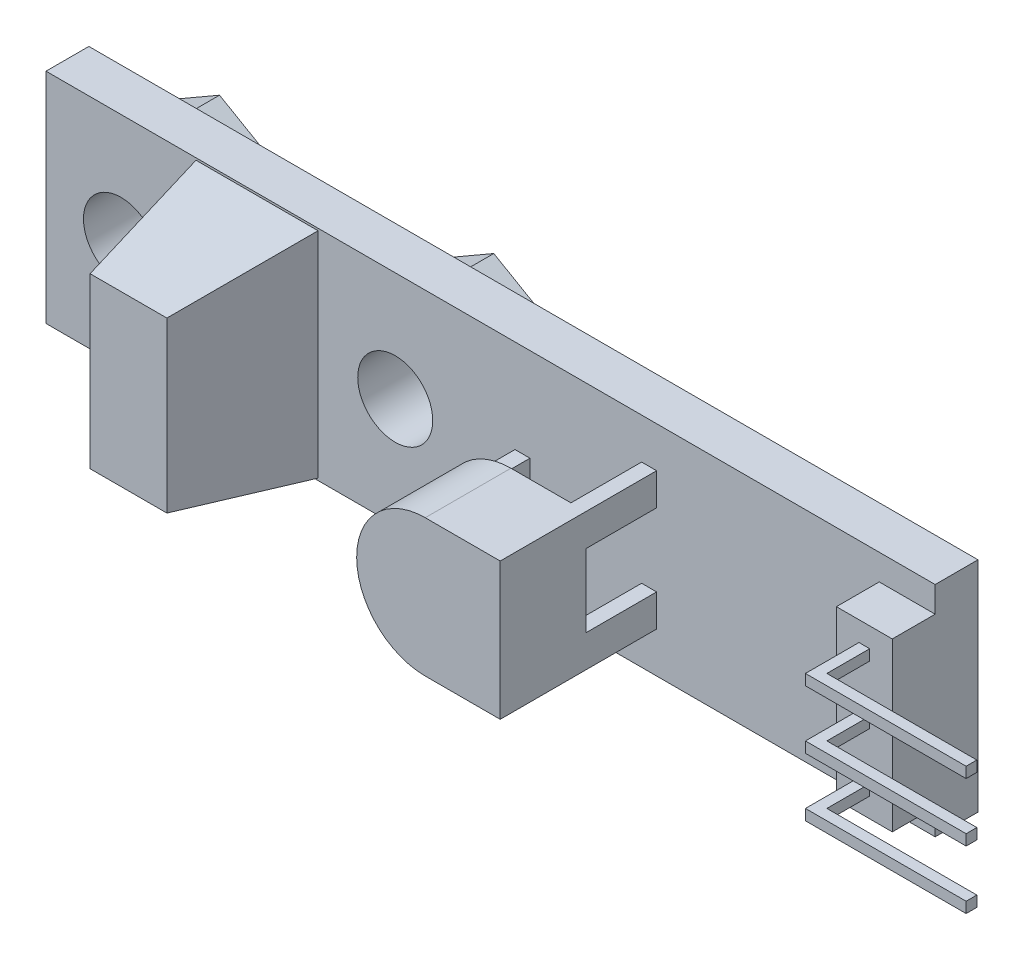
from build123d import *

# Parameters (mm, degrees)
ESBO_O1_W                = 41.5
ESBO_O1_H                = 10.2
ESBO_O1_R                = 1.75
RESSALTO_EXTRUS_O1_DEPTH = 2
ESBO_O2_W                = 5.7
ESBO_O2_H                = 10
RESSALTO_EXTRUS_O2_DEPTH = 6
RESSALTO_EXTRUS_O2_TAPER = 10
RESSALTO_EXTRUS_O3_DEPTH = 7.3
CORTE_EXTRUS_O1_START    = -4
CORTE_EXTRUS_O1_DEPTH    = 3.3
RESSALTO_EXTRUS_O4_DEPTH = 3.9
ESBO_O7_W                = 7.5
ESBO_O7_H                = 0.921500294
ESBO_O7_H_2              = 2.228499706
CORTE_EXTRUS_O2_DEPTH    = 2.5
ESBO_O8_R                = 1.75
RESSALTO_EXTRUS_O5_DEPTH = 2.6


with BuildPart() as part:
    # Esboço1 → Ressalto-extrusão1 (new body)
    with BuildSketch(Plane.XY):
        Rectangle(ESBO_O1_W, ESBO_O1_H)
        with Locations((-17.25, 0)):
            Circle(ESBO_O1_R, mode=Mode.SUBTRACT)
        with Locations((-4.45, 0)):
            Circle(ESBO_O1_R, mode=Mode.SUBTRACT)
    extrude(amount=RESSALTO_EXTRUS_O1_DEPTH)

    # Esboço2 → Ressalto-extrusão2 (add)
    with BuildSketch(Plane.XY.offset(2)):
        with Locations((-10.9, 0)):
            Rectangle(ESBO_O2_W, ESBO_O2_H)
    extrude(amount=RESSALTO_EXTRUS_O2_DEPTH, taper=RESSALTO_EXTRUS_O2_TAPER)

    # Esboço3 → Ressalto-extrusão3 (add)
    with BuildSketch(Plane.XY.offset(2)):
        with BuildLine():
            Line((4.25, 3.2), (7.75, 3.2))
            Line((7.75, 3.2), (7.75, -3.2))
            Line((7.75, -3.2), (4.25, -3.2))
            ThreePointArc((4.25, -3.2), (1.05, 0), (4.25, 3.2))
        make_face()
    extrude(amount=RESSALTO_EXTRUS_O3_DEPTH)

    # Esboço4 → Corte-extrusão1 (cut)
    with BuildSketch(Plane.XY.offset(9.3).offset(CORTE_EXTRUS_O1_START)):
        with BuildLine():
            Line((7.05, -3.2), (7.05, -1.7))
            Line((7.05, -1.7), (7.75, -1.7))
            Line((7.75, -1.7), (7.75, 1.7))
            Line((7.75, 1.7), (7.05, 1.7))
            Line((7.05, 1.7), (7.05, 3.2))
            Line((7.05, 3.2), (4.25, 3.2))
            ThreePointArc((4.25, 3.2), (2.270101013, 2.513961018), (1.139131954, 0.75))
            Line((1.139131954, 0.75), (1.839131954, 0.75))
            Line((1.839131954, 0.75), (1.839131954, -0.75))
            Line((1.839131954, -0.75), (1.139131954, -0.75))
            ThreePointArc((1.139131954, -0.75), (2.270101013, -2.513961018), (4.25, -3.2))
            Line((4.25, -3.2), (7.05, -3.2))
        make_face()
    extrude(amount=-CORTE_EXTRUS_O1_DEPTH, mode=Mode.SUBTRACT)

    # Esboço6 → Ressalto-extrusão4 (add, symmetric)
    with BuildSketch(Plane(origin=(0, 0, 0), x_dir=(1, 0, 0), z_dir=(0, 1, 0))):
        Polygon((18.141238668, -2), (18.141238668, -4), (19.195619334, -4), (19.195619334, -6.5), (26.695619334, -6.5), (26.695619334, -6), (19.695619334, -6), (19.695619334, -4), (20.75, -4), (20.75, -2), align=None)
    extrude(amount=RESSALTO_EXTRUS_O4_DEPTH, both=True)

    # Esboço7 → Corte-extrusão2 (cut)
    with BuildSketch(Plane.XY.offset(6.5)):
        with Locations((22.945619334, 3.439249853)):
            Rectangle(ESBO_O7_W, ESBO_O7_H)
        with Locations((22.945619334, 1.364249853)):
            Rectangle(ESBO_O7_W, ESBO_O7_H_2)
        with Locations((22.945619334, -1.364249853)):
            Rectangle(ESBO_O7_W, ESBO_O7_H_2)
        with Locations((22.945619334, -3.439249853)):
            Rectangle(ESBO_O7_W, ESBO_O7_H)
    extrude(amount=-CORTE_EXTRUS_O2_DEPTH, mode=Mode.SUBTRACT)

    # Esboço8 → Ressalto-extrusão5 (add)
    with BuildSketch(Plane(origin=(0, 0, 0), x_dir=(-1, 0, 0), z_dir=(0, 0, -1))):
        Polygon((7.55, 1.789785834), (4.45, 3.579571669), (1.35, 1.789785834), (1.35, -1.789785834), (4.45, -3.579571669), (7.55, -1.789785834), align=None)
        with Locations((4.45, 0)):
            Circle(ESBO_O8_R, mode=Mode.SUBTRACT)
        Polygon((14.15, -1.789785834), (17.25, -3.579571669), (20.35, -1.789785834), (20.35, 1.789785834), (17.25, 3.579571669), (14.15, 1.789785834), align=None)
        with Locations((17.25, 0)):
            Circle(ESBO_O8_R, mode=Mode.SUBTRACT)
    extrude(amount=RESSALTO_EXTRUS_O5_DEPTH)


solid = part.part
